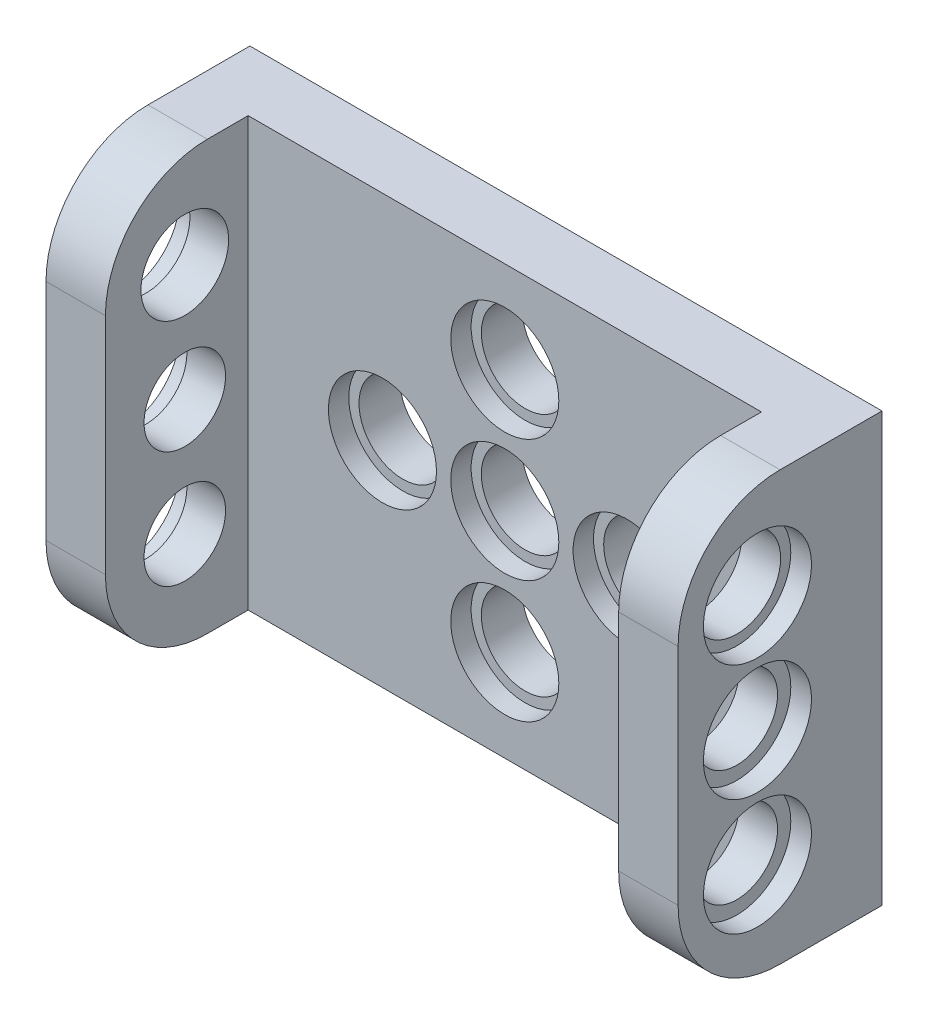
from build123d import *

# Parameters (mm, degrees)
CROQUIS1_W              = 31
CROQUIS1_H              = 21
SALIENTE_EXTRUIR1_DEPTH = 10
CROQUIS2_W              = 25.17
CROQUIS2_H              = 21
CORTAR_EXTRUIR1_DEPTH   = 7
CROQUIS5_R              = 2.15
CORTAR_EXTRUIR2_DEPTH   = 50.989400856
CROQUIS6_R              = 2
CROQUIS6_R_2            = 2.15
CORTAR_EXTRUIR4_DEPTH   = 39.950744164
CROQUIS6_3_R            = 2.65
CROQUIS6_3_R_2          = 2
CROQUIS6_3_R_3          = 2.15
CORTAR_EXTRUIR5_DEPTH   = 1.015
CORTAR_EXTRUIR6_START   = -1.015
CROQUIS9_R              = 2.65
CROQUIS9_R_2            = 2.15
CROQUIS9_R_3            = 2
CORTAR_EXTRUIR6_DEPTH   = 1.015
REDONDEO5_R             = 5
CORTAR_EXTRUIR8_START   = -1
CROQUIS10_R             = 2.65
CROQUIS10_R_2           = 2.15
CORTAR_EXTRUIR8_DEPTH   = 1


with BuildPart() as part:
    # Croquis1 → Saliente-Extruir1 (new body)
    with BuildSketch(Plane.XY):
        with Locations((28.576975021, 10.857913544)):
            Rectangle(CROQUIS1_W, CROQUIS1_H)
    extrude(amount=SALIENTE_EXTRUIR1_DEPTH)

    # Croquis2 → Cortar-Extruir1 (cut)
    with BuildSketch(Plane.XY.offset(10)):
        with Locations((28.576975021, 10.857913544)):
            Rectangle(CROQUIS2_W, CROQUIS2_H)
    extrude(amount=-CORTAR_EXTRUIR1_DEPTH, mode=Mode.SUBTRACT)

    # Croquis5 → Cortar-Extruir2 (cut, through all)
    with BuildSketch(Plane(origin=(0, 0, 0), x_dir=(-1, 0, 0), z_dir=(0, 0, -1))):
        with Locations((-28.576975021, 16.857913544)):
            Circle(CROQUIS5_R)
        with Locations((-22.576975021, 10.857913544)):
            Circle(CROQUIS5_R)
        with Locations((-34.576975021, 10.857913544)):
            Circle(CROQUIS5_R)
        with Locations((-28.576975021, 4.857913544)):
            Circle(CROQUIS5_R)
        with Locations((-28.576975021, 10.857913544)):
            Circle(CROQUIS5_R)
    extrude(amount=-CORTAR_EXTRUIR2_DEPTH, mode=Mode.SUBTRACT)

    # Croquis6 → Cortar-Extruir4 (cut, through all)
    with BuildSketch(Plane(origin=(44.076975021, 0, 0), x_dir=(0, 0, -1), z_dir=(1, 0, 0))):
        with Locations((-6.107568768, 5.142964849)):
            Circle(CROQUIS6_R)
        with Locations((-6.107568768, 10.857913544)):
            Circle(CROQUIS6_R)
        with Locations((-6.107568768, 16.572862239)):
            Circle(CROQUIS6_R_2)
    extrude(amount=-CORTAR_EXTRUIR4_DEPTH, mode=Mode.SUBTRACT)

    # Croquis6_3 → Cortar-Extruir5 (cut)
    # profile 1 of 3: a face of its own
    with BuildSketch(Plane(origin=(44.076975021, 0, 0), x_dir=(0, 0, -1), z_dir=(1, 0, 0))):
        with Locations((-6.107568768, 5.142964849)):
            Circle(CROQUIS6_3_R)
        with Locations((-6.107568768, 5.142964849)):
            Circle(CROQUIS6_3_R_2, mode=Mode.SUBTRACT)
    # profile 2 of 3: a face of its own
    with BuildSketch(Plane(origin=(44.076975021, 0, 0), x_dir=(0, 0, -1), z_dir=(1, 0, 0))):
        with Locations((-6.107568768, 10.857913544)):
            Circle(CROQUIS6_3_R)
        with Locations((-6.107568768, 10.857913544)):
            Circle(CROQUIS6_3_R_2, mode=Mode.SUBTRACT)
    # profile 3 of 3: a face of its own
    with BuildSketch(Plane(origin=(44.076975021, 0, 0), x_dir=(0, 0, -1), z_dir=(1, 0, 0))):
        with Locations((-6.107568768, 16.572862239)):
            Circle(CROQUIS6_3_R)
        with Locations((-6.107568768, 16.572862239)):
            Circle(CROQUIS6_3_R_3, mode=Mode.SUBTRACT)
    extrude(amount=-CORTAR_EXTRUIR5_DEPTH, mode=Mode.SUBTRACT)

    # Croquis9 → Cortar-Extruir6 (cut)
    # profile 1 of 3: a face of its own
    with BuildSketch(Plane.ZY.offset(-13.076975021).offset(CORTAR_EXTRUIR6_START)):
        with Locations((6.107568768, 16.572862239)):
            Circle(CROQUIS9_R)
        with Locations((6.107568768, 16.572862239)):
            Circle(CROQUIS9_R_2, mode=Mode.SUBTRACT)
    # profile 2 of 3: a face of its own
    with BuildSketch(Plane.ZY.offset(-13.076975021).offset(CORTAR_EXTRUIR6_START)):
        with Locations((6.107568768, 10.857913544)):
            Circle(CROQUIS9_R)
        with Locations((6.107568768, 10.857913544)):
            Circle(CROQUIS9_R_3, mode=Mode.SUBTRACT)
    # profile 3 of 3: a face of its own
    with BuildSketch(Plane.ZY.offset(-13.076975021).offset(CORTAR_EXTRUIR6_START)):
        with Locations((6.107568768, 5.142964849)):
            Circle(CROQUIS9_R)
        with Locations((6.107568768, 5.142964849)):
            Circle(CROQUIS9_R_3, mode=Mode.SUBTRACT)
    extrude(amount=CORTAR_EXTRUIR6_DEPTH, mode=Mode.SUBTRACT)

    # Redondeo5
    redondeo5_edges = [part.edges().sort_by_distance(p)[0] for p in [
        (14.534475021, 0.357913544, 10),
        (42.619475021, 0.357913544, 10),
        (42.619475021, 21.357913544, 10),
        (14.534475021, 21.357913544, 10),
    ]]
    fillet(redondeo5_edges, radius=REDONDEO5_R)

    # Croquis10 → Cortar-Extruir8 (cut)
    # profile 1 of 5: a face of its own
    with BuildSketch(Plane.XY.offset(3).offset(CORTAR_EXTRUIR8_START)):
        with Locations((28.576975021, 16.857913544)):
            Circle(CROQUIS10_R)
        with Locations((28.576975021, 16.857913544)):
            Circle(CROQUIS10_R_2, mode=Mode.SUBTRACT)
    # profile 2 of 5: a face of its own
    with BuildSketch(Plane.XY.offset(3).offset(CORTAR_EXTRUIR8_START)):
        with Locations((34.576975021, 10.857913544)):
            Circle(CROQUIS10_R)
        with Locations((34.576975021, 10.857913544)):
            Circle(CROQUIS10_R_2, mode=Mode.SUBTRACT)
    # profile 3 of 5: a face of its own
    with BuildSketch(Plane.XY.offset(3).offset(CORTAR_EXTRUIR8_START)):
        with Locations((28.576975021, 10.857913544)):
            Circle(CROQUIS10_R)
        with Locations((28.576975021, 10.857913544)):
            Circle(CROQUIS10_R_2, mode=Mode.SUBTRACT)
    # profile 4 of 5: a face of its own
    with BuildSketch(Plane.XY.offset(3).offset(CORTAR_EXTRUIR8_START)):
        with Locations((22.576975021, 10.857913544)):
            Circle(CROQUIS10_R)
        with Locations((22.576975021, 10.857913544)):
            Circle(CROQUIS10_R_2, mode=Mode.SUBTRACT)
    # profile 5 of 5: a face of its own
    with BuildSketch(Plane.XY.offset(3).offset(CORTAR_EXTRUIR8_START)):
        with Locations((28.576975021, 4.857913544)):
            Circle(CROQUIS10_R)
        with Locations((28.576975021, 4.857913544)):
            Circle(CROQUIS10_R_2, mode=Mode.SUBTRACT)
    extrude(amount=CORTAR_EXTRUIR8_DEPTH, mode=Mode.SUBTRACT)


solid = part.part
